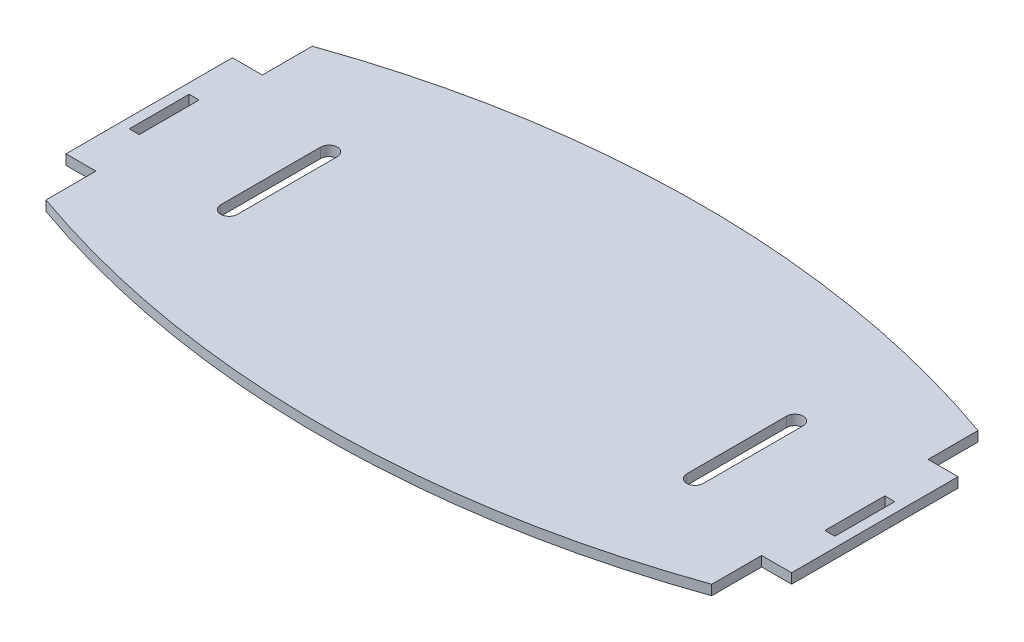
from build123d import *

# Parameters (mm, degrees)
SKETCH1_W           = 3
SKETCH1_H           = 18
BOSS_EXTRUDE1_DEPTH = 3


with BuildPart() as part:
    # Sketch1 → Boss-Extrude1 (new body)
    with BuildSketch(Plane(origin=(0, 0, 0), x_dir=(1, 0, 0), z_dir=(0, 1, 0))):
        with BuildLine():
            Line((-100, 40), (-100, 25))
            Line((-100, 25), (-109, 25))
            Line((-109, 25), (-109, -25))
            Line((-109, -25), (-100, -25))
            Line((-100, -25), (-100, -40))
            ThreePointArc((-100, -40), (0, -57.157287525), (100, -40))
            Line((100, -40), (100, -25))
            Line((100, -25), (109, -25))
            Line((109, -25), (109, 25))
            Line((109, 25), (100, 25))
            Line((100, 25), (100, 40))
            ThreePointArc((100, 40), (0, 57.157287525), (-100, 40))
        make_face()
        with Locations((104.5, 0)):
            Rectangle(SKETCH1_W, SKETCH1_H, mode=Mode.SUBTRACT)
        with Locations((-104.5, 0)):
            Rectangle(SKETCH1_W, SKETCH1_H, mode=Mode.SUBTRACT)
        with BuildLine():
            Line((-72.5, -15), (-72.5, 15))
            ThreePointArc((-72.5, 15), (-70, 17.5), (-67.5, 15))
            Line((-67.5, 15), (-67.5, -15))
            ThreePointArc((-67.5, -15), (-70, -17.5), (-72.5, -15))
        make_face(mode=Mode.SUBTRACT)
        with BuildLine():
            Line((72.5, -15), (72.5, 15))
            ThreePointArc((72.5, 15), (70, 17.5), (67.5, 15))
            Line((67.5, 15), (67.5, -15))
            ThreePointArc((67.5, -15), (70, -17.5), (72.5, -15))
        make_face(mode=Mode.SUBTRACT)
    extrude(amount=BOSS_EXTRUDE1_DEPTH)


solid = part.part
